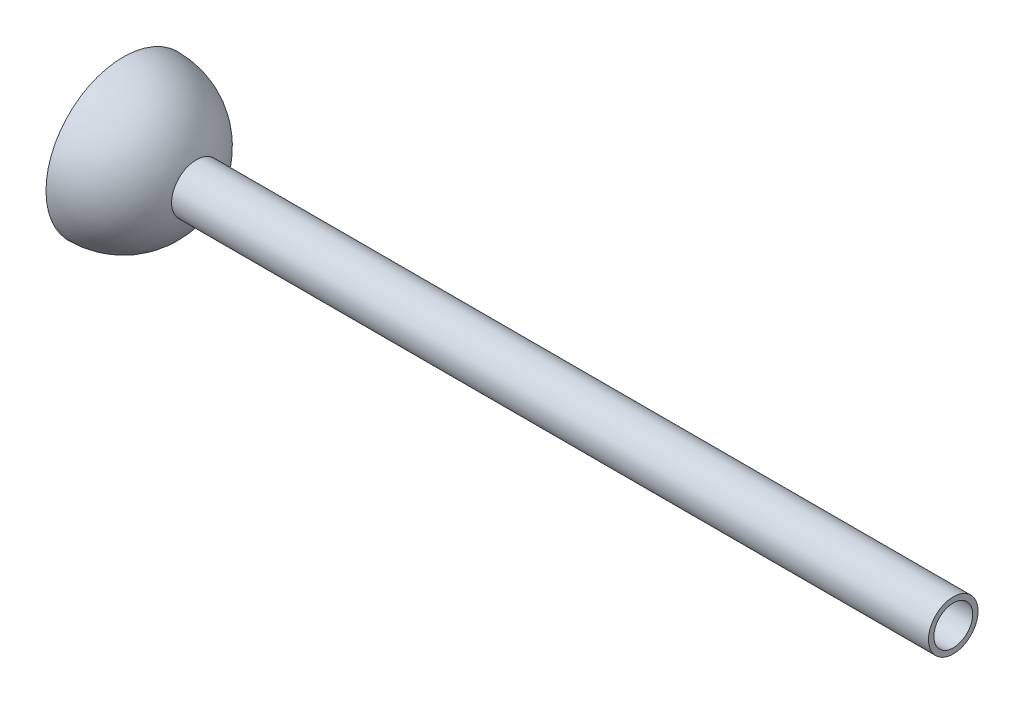
from build123d import *


with BuildPart() as part:
    # Sketch1 → Revolve1 (revolve)
    with BuildSketch(Plane(origin=(0, 0, 0), x_dir=(1, 0, 0), z_dir=(0, 1, 0))):
        with BuildLine():
            Line((0, 12.7), (0, 10.795))
            ThreePointArc((0, 10.795), (7.633217703, 7.633217703), (10.795, 0))
            Line((10.795, 0), (12.7, 0))
            ThreePointArc((12.7, 0), (12.597580707, 1.609646024), (12.291974752, 3.193330031))
            Line((12.291974752, 3.193330031), (136.525, 3.193330031))
            Line((136.525, 3.193330031), (136.525, 4.074251535))
            Line((136.525, 4.074251535), (12.028735363, 4.074251535))
            ThreePointArc((12.028735363, 4.074251535), (7.400912292, 10.320682983), (0, 12.7))
        make_face()
    revolve(axis=Axis((0, 0, 0), (1, 0, 0)))


solid = part.part
